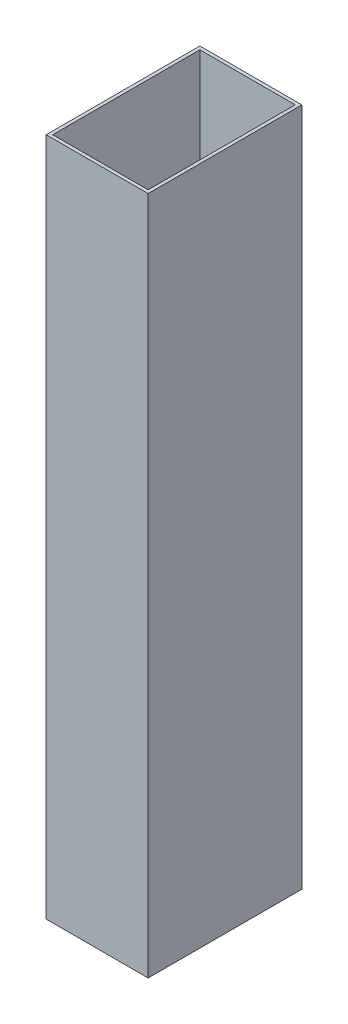
from build123d import *

# Parameters (mm, degrees)
CROQUIS1_W              = 63
CROQUIS1_H              = 95
CROQUIS1_W_2            = 59
CROQUIS1_H_2            = 91
SALIENTE_EXTRUIR1_DEPTH = 420


with BuildPart() as part:
    # Croquis1 → Saliente-Extruir1 (new body)
    with BuildSketch(Plane(origin=(0, 0, 0), x_dir=(1, 0, 0), z_dir=(0, 1, 0))):
        Rectangle(CROQUIS1_W, CROQUIS1_H)
        Rectangle(CROQUIS1_W_2, CROQUIS1_H_2, mode=Mode.SUBTRACT)
    extrude(amount=SALIENTE_EXTRUIR1_DEPTH)


solid = part.part
